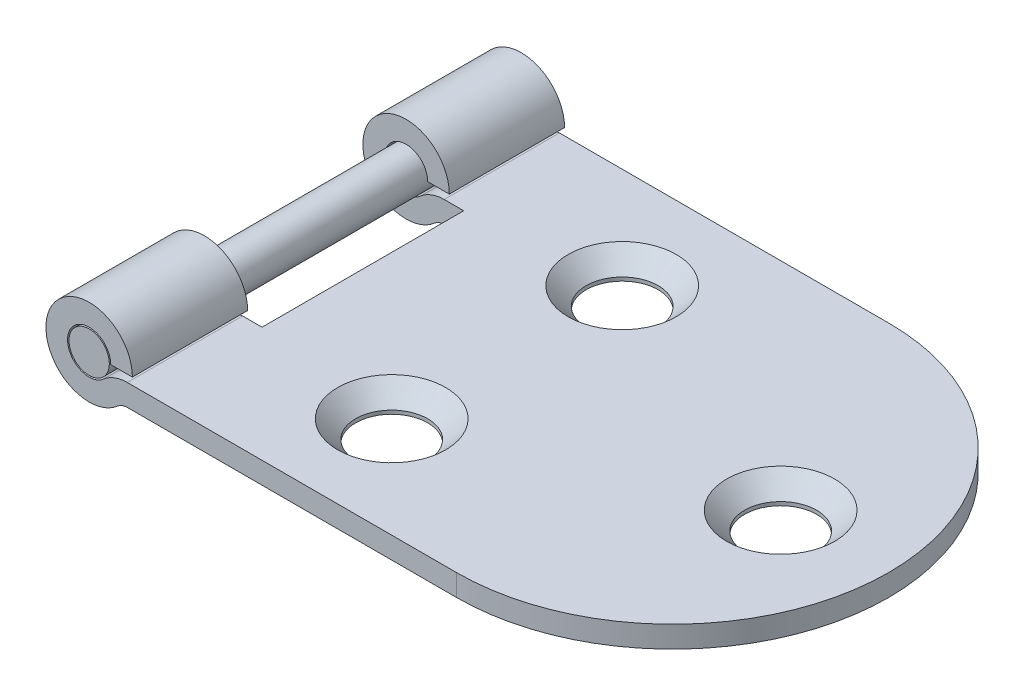
from build123d import *

# Parameters (mm, degrees)
BODY_DEPTH                    = 15
SKETCH_2_R                    = 2.5
CUT_1_DEPTH                   = 30
HOLE_WIZARD_7_5_5_D           = 5
HOLE_WIZARD_7_5_5_DEPTH       = 8.5
HOLE_WIZARD_7_5_5_CSINK_D     = 7.5
HOLE_WIZARD_7_5_5_CSINK_ANGLE = 90
HOLE_WIZARD_7_5_5_TIP         = 1.502151548
SKETCH_4_W                    = 8
SKETCH_4_H                    = 14
CUT_EXTRUDE_2_DEPTH           = 15
EXTRUDE_1_REACH               = 17
SKETCH_6_R                    = 1.4
EXTRUDE_1_DIRECTION_2_REACH   = 17


with BuildPart() as part:
    # ｽｹｯﾁ1 → BODY (new body, symmetric)
    with BuildSketch(Plane.XY):
        with BuildLine():
            Line((2.645751311, 1.5), (40.5, 1.5))
            Line((40.5, 1.5), (40.5, 0))
            Line((40.5, 0), (2.645751311, 0))
            ThreePointArc((2.645751311, 0), (2.29219792, -0.064585653), (1.984313483, -0.25))
            ThreePointArc((1.984313483, -0.25), (-2.734313483, 3.234313483), (3, 2))
            Line((3, 2), (1.5, 2))
            ThreePointArc((1.5, 2), (-1.367156742, 2.617156742), (0.992156742, 0.875))
            ThreePointArc((0.992156742, 0.875), (1.761867835, 1.338535867), (2.645751311, 1.5))
        make_face()
    extrude(amount=BODY_DEPTH, both=True)

    # ｽｹｯﾁ2 → CUT-1 (cut)
    with BuildSketch(Plane(origin=(0, 1.5, 0), x_dir=(1, 0, 0), z_dir=(0, 1, 0))):
        with Locations((33, 0)):
            Circle(SKETCH_2_R)
        with Locations((14, 8)):
            Circle(SKETCH_2_R)
        with Locations((14, -8)):
            Circle(SKETCH_2_R)
        with BuildLine():
            Line((40.5, -15), (40.5, 0))
            ThreePointArc((40.5, 0), (36.106601718, -10.606601718), (25.5, -15))
            Line((25.5, -15), (40.5, -15))
        make_face()
        with BuildLine():
            Line((40.5, 15), (25.5, 15))
            ThreePointArc((25.5, 15), (36.106601718, 10.606601718), (40.5, 0))
            Line((40.5, 0), (40.5, 15))
        make_face()
    extrude(amount=-CUT_1_DEPTH, mode=Mode.SUBTRACT)

    # φ7.5-φ5
    with Locations(Plane(origin=(14, 1.5, -8), x_dir=(1, 0, 0), z_dir=(0, 1, 0))):
        with Locations((0, 0), (0, -16), (19, -8)):
            CounterSinkHole(HOLE_WIZARD_7_5_5_D / 2, HOLE_WIZARD_7_5_5_CSINK_D / 2, depth=HOLE_WIZARD_7_5_5_DEPTH, counter_sink_angle=HOLE_WIZARD_7_5_5_CSINK_ANGLE)
            with Locations((0, 0, -(HOLE_WIZARD_7_5_5_DEPTH + HOLE_WIZARD_7_5_5_TIP / 2))):  # 118° drill point
                Cone(0, HOLE_WIZARD_7_5_5_D / 2, HOLE_WIZARD_7_5_5_TIP, mode=Mode.SUBTRACT)

    # ｽｹｯﾁ4 → ｶｯﾄ - 押し出し2 (cut, symmetric)
    with BuildSketch(Plane(origin=(0, 1.5, 0), x_dir=(1, 0, 0), z_dir=(0, 1, 0))):
        Rectangle(SKETCH_4_W, SKETCH_4_H)
    extrude(amount=CUT_EXTRUDE_2_DEPTH, both=True, mode=Mode.SUBTRACT)


with BuildPart() as body_2:

    # ﾎﾞｽ - 押し出し1: up to this face of the body (flat: up to its plane)
    extrude_1_end = Plane(part.part.faces().sort_by_distance((8.809859415, 1.217701285, 15))[0])
    # ｽｹｯﾁ6 → ﾎﾞｽ - 押し出し1 (new body, up to the picked face)
    with BuildSketch(Plane.XY, mode=Mode.PRIVATE) as extrude_1_sk1:
        with Locations((0, 2)):
            Circle(SKETCH_6_R)
    extrude_1_tool1 = split(extrude(extrude_1_sk1.sketch, amount=EXTRUDE_1_REACH, mode=Mode.PRIVATE), bisect_by=extrude_1_end, keep=Keep.BOTH, mode=Mode.PRIVATE)
    add(extrude_1_tool1.solids().sort_by_distance((0, 2, 0))[0])


    # ﾎﾞｽ - 押し出し1 direction 2: up to this face of the body (flat: up to its plane)
    extrude_1_direction_2_end = Plane(part.part.faces().sort_by_distance((8.809859415, 1.217701285, -15))[0])
    # ｽｹｯﾁ6 → ﾎﾞｽ - 押し出し1 direction 2 (add, up to the picked face)
    with BuildSketch(Plane.XY, mode=Mode.PRIVATE) as extrude_1_direction_2_sk1:
        with Locations((0, 2)):
            Circle(SKETCH_6_R)
    extrude_1_direction_2_tool1 = split(extrude(extrude_1_direction_2_sk1.sketch, amount=-EXTRUDE_1_DIRECTION_2_REACH, mode=Mode.PRIVATE), bisect_by=extrude_1_direction_2_end, keep=Keep.BOTH, mode=Mode.PRIVATE)
    add(extrude_1_direction_2_tool1.solids().sort_by_distance((0, 2, 0))[0])


solid = Compound([part.part, body_2.part])
